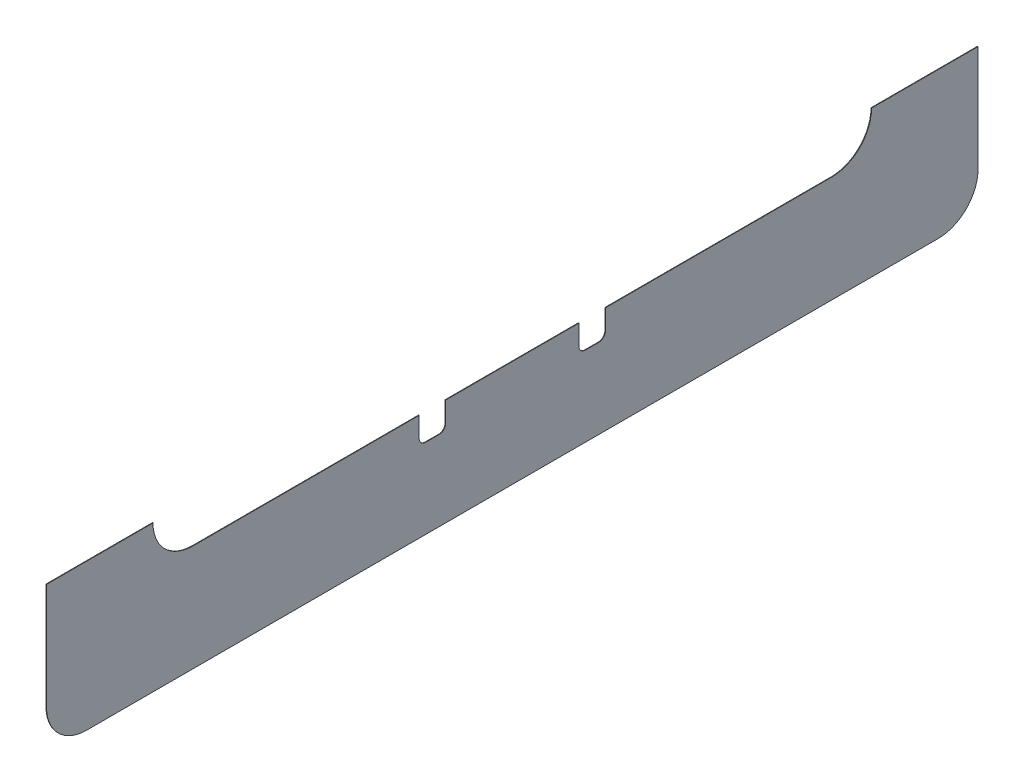
from build123d import *

# Parameters (mm, degrees)
BOSS_EXTRUDE2_DEPTH = 0.254
CUT_EXTRUDE1_DEPTH  = 1.254
SKETCH13_W          = 444.5
SKETCH13_H          = 215.9
CUT_EXTRUDE3_DEPTH  = 1.254


with BuildPart() as part:
    # Sketch1 → Boss-Extrude2 (new body)
    with BuildSketch(Plane(origin=(0, 0, 0), x_dir=(0, 0, -1), z_dir=(1, 0, 0))):
        with BuildLine():
            Line((-222.25, 0), (-171.45, 0))
            Line((-171.45, 0), (-171.45, -215.9))
            ThreePointArc((-171.45, -215.9), (-165.870384182, -229.370384182), (-152.4, -234.95))
            Line((-152.4, -234.95), (152.4, -234.95))
            ThreePointArc((152.4, -234.95), (165.870384182, -229.370384182), (171.45, -215.9))
            Line((171.45, -215.9), (171.45, 0))
            Line((171.45, 0), (222.25, 0))
            Line((222.25, 0), (222.25, -266.7))
            ThreePointArc((222.25, -266.7), (216.670384182, -280.170384182), (203.2, -285.75))
            Line((203.2, -285.75), (-203.2, -285.75))
            ThreePointArc((-203.2, -285.75), (-216.670384182, -280.170384182), (-222.25, -266.7))
            Line((-222.25, -266.7), (-222.25, 0))
        make_face()
    extrude(amount=BOSS_EXTRUDE2_DEPTH)

    # Sketch11 → Cut-Extrude1 (cut, through all)
    with BuildSketch(Plane.ZY):
        with BuildLine():
            Line((-171.45, -103.759), (-180.975, -103.759))
            ThreePointArc((-180.975, -103.759), (-183.22006403, -104.68893597), (-184.15, -106.934))
            Line((-184.15, -106.934), (-184.15, -133.604))
            ThreePointArc((-184.15, -133.604), (-183.22006403, -135.84906403), (-180.975, -136.779))
            Line((-180.975, -136.779), (-171.45, -136.779))
            Line((-171.45, -136.779), (-171.45, -103.759))
        make_face()
        with BuildLine():
            Line((-44.45, -234.95), (-31.75, -234.95))
            Line((-31.75, -234.95), (-31.75, -244.475))
            ThreePointArc((-31.75, -244.475), (-32.67993597, -246.72006403), (-34.925, -247.65))
            Line((-34.925, -247.65), (-41.275, -247.65))
            ThreePointArc((-41.275, -247.65), (-43.52006403, -246.72006403), (-44.45, -244.475))
            Line((-44.45, -244.475), (-44.45, -234.95))
        make_face()
    cut_extrude1 = extrude(amount=-CUT_EXTRUDE1_DEPTH, mode=Mode.SUBTRACT)

    # Mirror2: Cut-Extrude1 across plane
    add(cut_extrude1.mirror(Plane.XY), mode=Mode.SUBTRACT)

    # Sketch13 → Cut-Extrude3 (cut, through all)
    with BuildSketch(Plane.ZY):
        with Locations((0, -107.95)):
            Rectangle(SKETCH13_W, SKETCH13_H)
    extrude(amount=-CUT_EXTRUDE3_DEPTH, mode=Mode.SUBTRACT)


solid = part.part
